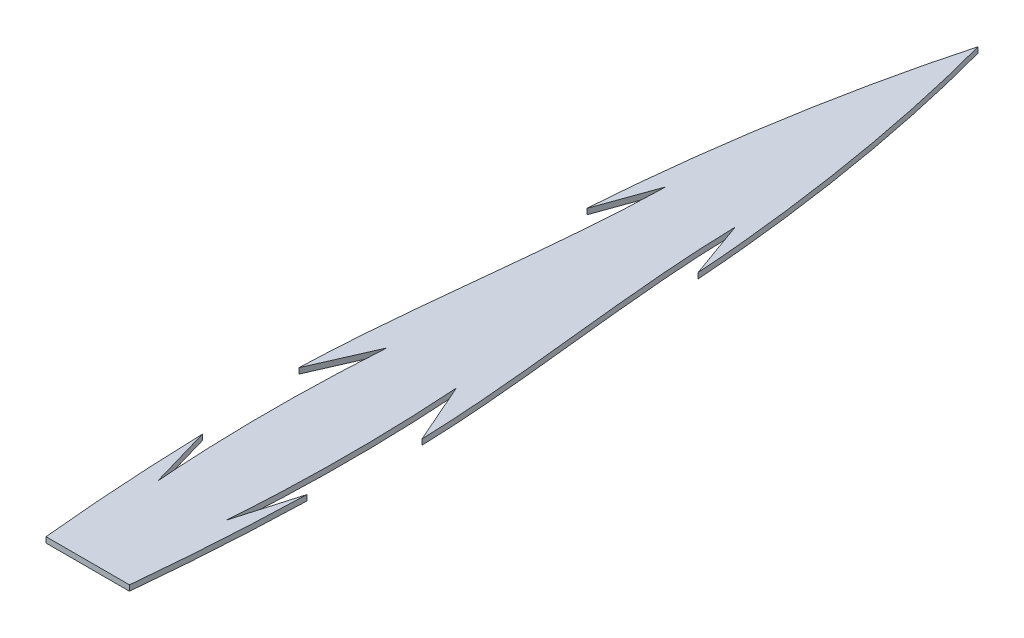
from build123d import *

# Parameters (mm, degrees)
BOSS_EXTRUDE1_DEPTH = 0.635


with BuildPart() as part:
    # Sketch1 → Boss-Extrude1 (new body)
    with BuildSketch(Plane(origin=(0, 0, 0), x_dir=(1, 0, 0), z_dir=(0, 1, 0))):
        with BuildLine():
            Line((-4.7625, 0), (0, 0))
            Line((0, 0), (0, 101.6))
            add(Edge.make_bspline(
                [(0, 101.6), (-3.29157344, 89.553724647), (-5.507928579, 75.631531474), (-6.342018648, 63.306201638)],
                knots=[0, 0, 0, 0, 1, 1, 1, 1], degree=3))
            Line((-6.342018648, 63.306201638), (-3.96875, 69.932898034))
            add(Edge.make_bspline(
                [(-3.96875, 69.932898034), (-4.226464503, 57.224491344), (-6.645417813, 43.863409348), (-7.029062123, 31.123476805)],
                knots=[0, 0, 0, 0, 1, 1, 1, 1], degree=3))
            Line((-7.029062123, 31.123476805), (-3.96875, 38.1))
            add(Edge.make_bspline(
                [(-3.96875, 38.1), (-4.867929466, 24.545209762), (-3.889947106, 11.87670313)],
                knots=[0, 0, 0, 1, 1, 1], degree=2))
            add(Edge.make_bspline(
                [(-3.889947106, 11.87670313), (-5.03752141, 15.708655714), (-5.969, 19.05)],
                knots=[0, 0, 0, 1, 1, 1], degree=2))
            add(Edge.make_bspline(
                [(-4.7625, 0), (-5.706405824, 9.509529369), (-5.969, 19.05)],
                knots=[0, 0, 0, 1, 1, 1], degree=2))
        make_face()
        with BuildLine():
            Line((0, 101.6), (0, 0))
            Line((0, 0), (4.7625, 0))
            add(Edge.make_bspline(
                [(4.7625, 0), (5.706405824, 9.509529369), (5.969, 19.05)],
                knots=[0, 0, 0, 1, 1, 1], degree=2))
            add(Edge.make_bspline(
                [(3.889947106, 11.87670313), (5.03752141, 15.708655714), (5.969, 19.05)],
                knots=[0, 0, 0, 1, 1, 1], degree=2))
            add(Edge.make_bspline(
                [(3.96875, 38.1), (4.867929466, 24.545209762), (3.889947106, 11.87670313)],
                knots=[0, 0, 0, 1, 1, 1], degree=2))
            Line((3.96875, 38.1), (7.029062123, 31.123476805))
            add(Edge.make_bspline(
                [(3.96875, 69.932898034), (4.226464503, 57.224491344), (6.645417813, 43.863409348), (7.029062123, 31.123476805)],
                knots=[0, 0, 0, 0, 1, 1, 1, 1], degree=3))
            Line((3.96875, 69.932898034), (6.342018648, 63.306201638))
            add(Edge.make_bspline(
                [(0, 101.6), (3.29157344, 89.553724647), (5.507928579, 75.631531474), (6.342018648, 63.306201638)],
                knots=[0, 0, 0, 0, 1, 1, 1, 1], degree=3))
        make_face()
    extrude(amount=BOSS_EXTRUDE1_DEPTH)


solid = part.part
